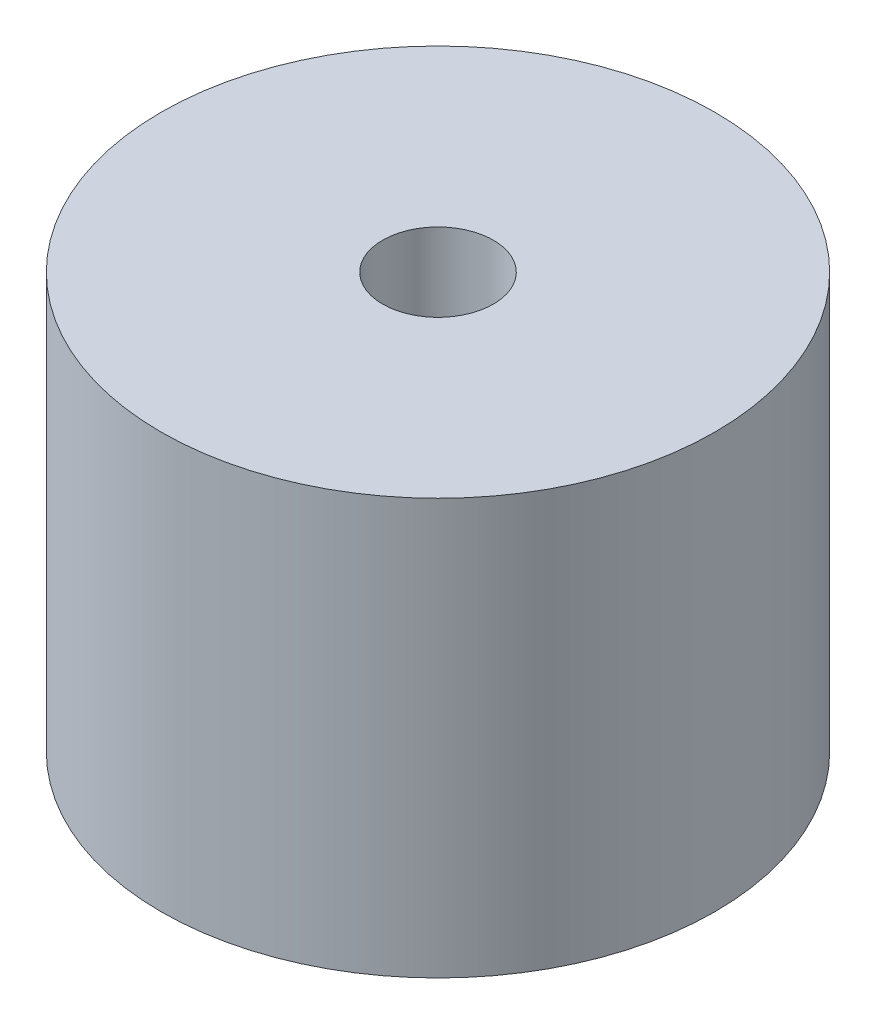
from build123d import *

# Parameters (mm, degrees)
SKETCH2_R           = 10
SKETCH2_R_2         = 2
BOSS_EXTRUDE1_DEPTH = 15


with BuildPart() as part:
    # Sketch2 → Boss-Extrude1 (new body)
    with BuildSketch(Plane(origin=(0, 0, 0), x_dir=(1, 0, 0), z_dir=(0, 1, 0))):
        Circle(SKETCH2_R)
        Circle(SKETCH2_R_2, mode=Mode.SUBTRACT)
    extrude(amount=BOSS_EXTRUDE1_DEPTH)


solid = part.part
